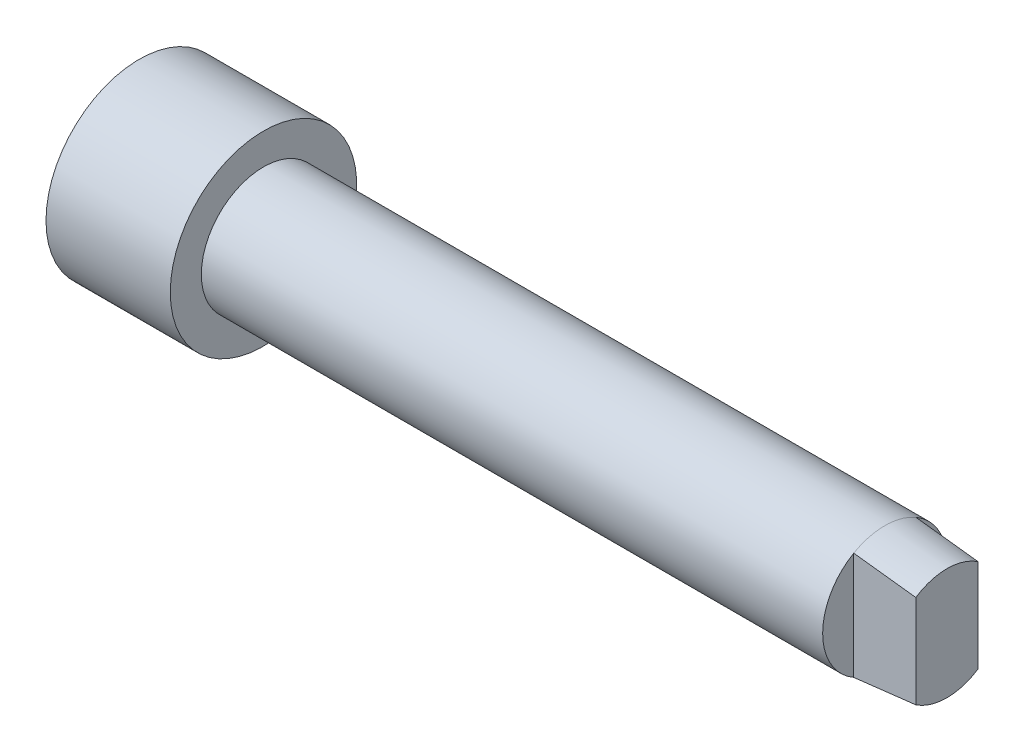
from build123d import *

# Parameters (mm, degrees)
SKETCH2_W          = 2.5
SKETCH2_H          = 8.660254038
CUT_EXTRUDE1_DEPTH = 5


with BuildPart() as part:
    # Sketch1 → Revolve1 (revolve)
    with BuildSketch(Plane.XY):
        Polygon((-5, 5), (-5, 0), (0, 0), (0, 5), (0, 7.5), (-10, 7.5), (-10, 5), align=None)
        Polygon((50, 5), (0, 5), (0, 0), (55, 0), (55, 4.5), align=None)
    revolve(axis=Axis((0, 0, 0), (1, 0, 0)))

    # Sketch2 → Cut-Extrude1 (cut)
    with BuildSketch(Plane(origin=(55, 0, 0), x_dir=(0, 0, -1), z_dir=(1, 0, 0))):
        with Locations((-3.75, 0)):
            Rectangle(SKETCH2_W, SKETCH2_H)
        with Locations((3.75, 0)):
            Rectangle(SKETCH2_W, SKETCH2_H)
    extrude(amount=-CUT_EXTRUDE1_DEPTH, mode=Mode.SUBTRACT)


solid = part.part
